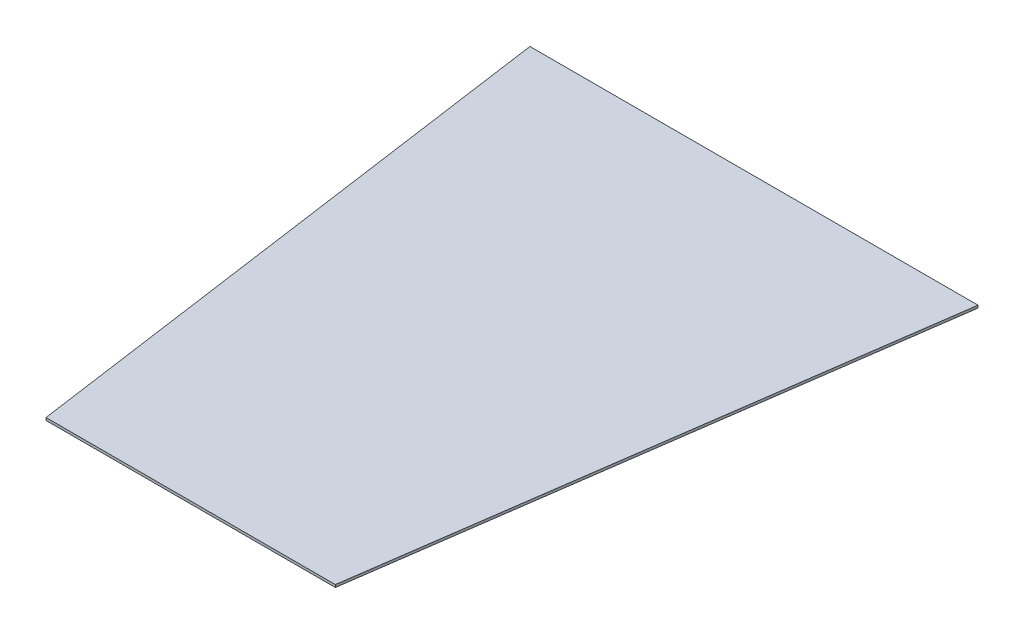
from build123d import *

# Parameters (mm, degrees)
BOSS_EXTRUDE1_DEPTH = 5


with BuildPart() as part:
    # Sketch1 → Boss-Extrude1 (new body)
    with BuildSketch(Plane(origin=(0, 0, 0), x_dir=(1, 0, 0), z_dir=(0, 1, 0))):
        Polygon((-415.943687572, 350), (-260.943687572, -750), (304.056312428, -750), (459.056312428, 350), align=None)
    extrude(amount=BOSS_EXTRUDE1_DEPTH)


solid = part.part
